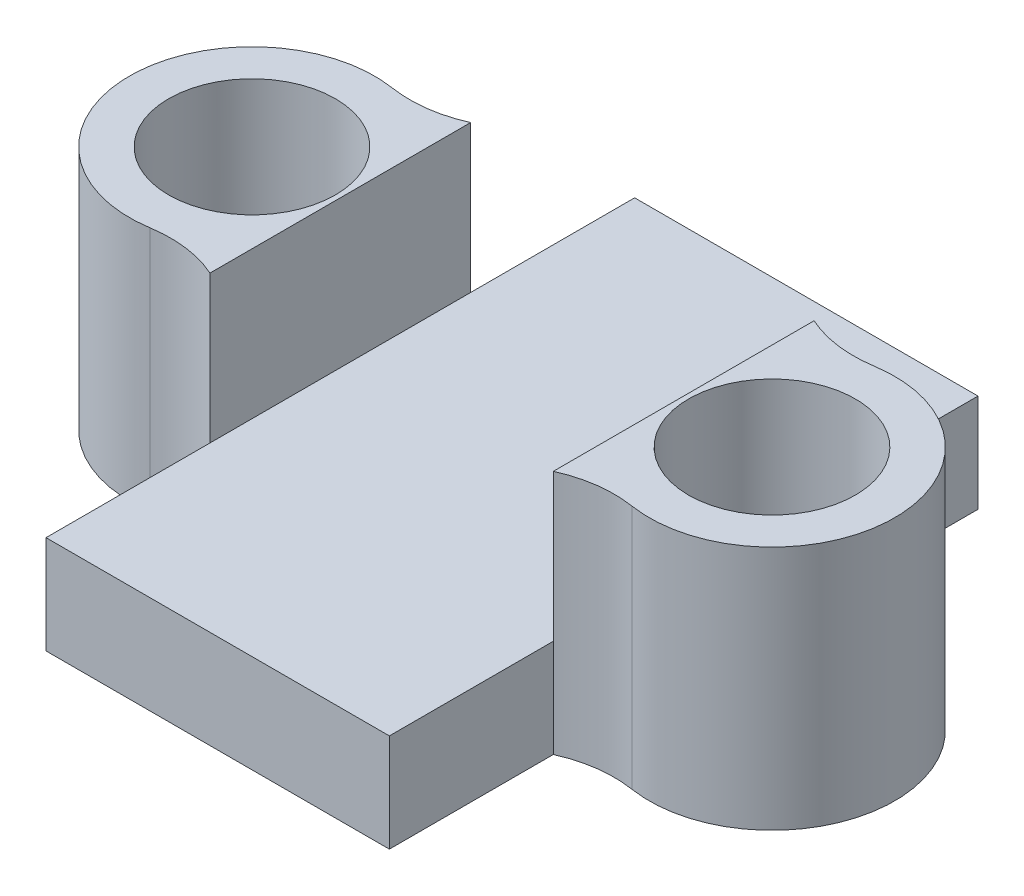
from build123d import *
from build123d.topology import SkipClean

# Parameters (mm, degrees)
CROQUIS1_R              = 1.7
SALIENTE_EXTRUIR1_DEPTH = 2
CROQUIS5_R              = 1.7
BOSS_EXTRUDE1_DEPTH     = 3


with BuildPart() as part:
    # Croquis1 → Saliente-Extruir1 (new body)
    with BuildSketch(Plane(origin=(0, 0, 0), x_dir=(1, 0, 0), z_dir=(0, 1, 0))):
        with BuildLine():
            Line((-3.5, 6), (3.5, 6))
            Line((3.5, 6), (3.5, 2.657498126))
            ThreePointArc((3.5, 2.657498126), (4.191822894, 2.460979566), (4.910964812, 2.469544821))
            ThreePointArc((4.910964812, 2.469544821), (7.8, 0), (4.910964812, -2.469544821))
            ThreePointArc((4.910964812, -2.469544821), (4.191822894, -2.460979566), (3.5, -2.657498126))
            Line((3.5, -2.657498126), (3.5, -6))
            Line((3.5, -6), (-3.5, -6))
            Line((-3.5, -6), (-3.5, -2.657498126))
            ThreePointArc((-3.5, -2.657498126), (-4.191822894, -2.460979566), (-4.910964812, -2.469544821))
            ThreePointArc((-4.910964812, -2.469544821), (-7.8, 0), (-4.910964812, 2.469544821))
            ThreePointArc((-4.910964812, 2.469544821), (-4.191822894, 2.460979566), (-3.5, 2.657498126))
            Line((-3.5, 2.657498126), (-3.5, 6))
        make_face()
        with Locations((5.3, 0)):
            Circle(CROQUIS1_R, mode=Mode.SUBTRACT)
        with Locations((-5.3, 0)):
            Circle(CROQUIS1_R, mode=Mode.SUBTRACT)
    extrude(amount=SALIENTE_EXTRUIR1_DEPTH)

    # Croquis5 → Boss-Extrude1 (add)
    # profile 1 of 2: a face of its own
    with SkipClean():  # the faces are left unmerged after this step: merging them gives an invalid solid
        with BuildSketch(Plane(origin=(0, 2, 0), x_dir=(1, 0, 0), z_dir=(0, 1, 0))):
            with BuildLine():
                Line((3.5, 2.657498126), (3.5, -2.657498126))
                ThreePointArc((3.5, -2.657498126), (4.191822894, -2.460979566), (4.910964812, -2.469544821))
                ThreePointArc((4.910964812, -2.469544821), (7.8, 0), (4.910964812, 2.469544821))
                ThreePointArc((4.910964812, 2.469544821), (4.191822894, 2.460979566), (3.5, 2.657498126))
            make_face()
            with Locations((5.3, 0)):
                Circle(CROQUIS5_R, mode=Mode.SUBTRACT)
        # profile 2 of 2: a face of its own
        with BuildSketch(Plane(origin=(0, 2, 0), x_dir=(1, 0, 0), z_dir=(0, 1, 0))):
            with BuildLine():
                ThreePointArc((-4.910964812, -2.469544821), (-4.191822894, -2.460979566), (-3.5, -2.657498126))
                Line((-3.5, -2.657498126), (-3.5, 2.657498126))
                ThreePointArc((-3.5, 2.657498126), (-4.191822894, 2.460979566), (-4.910964812, 2.469544821))
                ThreePointArc((-4.910964812, 2.469544821), (-7.8, 0), (-4.910964812, -2.469544821))
            make_face()
            with Locations((-5.3, 0)):
                Circle(CROQUIS5_R, mode=Mode.SUBTRACT)
        extrude(amount=BOSS_EXTRUDE1_DEPTH)


solid = part.part
